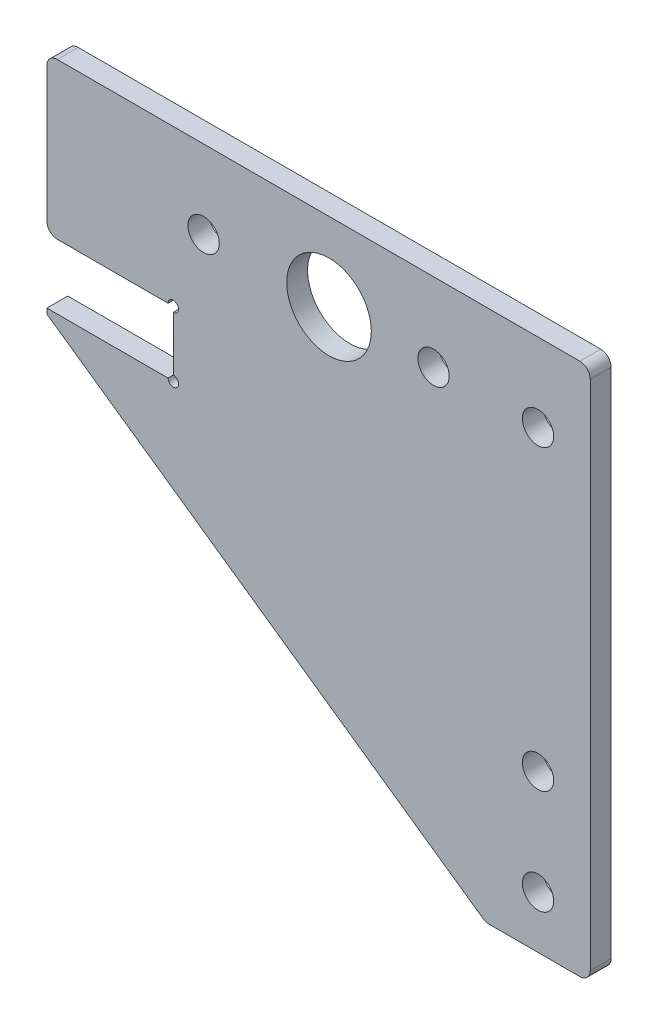
from build123d import *

# Parameters (mm, degrees)
SKETCH_1_R          = 1.5
SKETCH_1_R_2        = 4.05
EXTRUDE_1_DEPTH     = 2
SKETCH_2_R          = 0.5
CUT_EXTRUDE_1_DEPTH = 10
FILLET_1_R          = 1


with BuildPart() as part:
    # 草图1 → 凸台-拉伸1 (new body)
    with BuildSketch(Plane.XY):
        Polygon((-47, -14.091283395), (-5, -43.5), (5, -43.5), (5, 7.5), (-47, 7.5), (-47, -7.4), (-34.9, -7.4), (-34.9, -13.6), (-47, -13.6), align=None)
        with Locations((0, -38.5)):
            Circle(SKETCH_1_R, mode=Mode.SUBTRACT)
        with Locations((0, -28.5)):
            Circle(SKETCH_1_R, mode=Mode.SUBTRACT)
        with Locations((-32, 0)):
            Circle(SKETCH_1_R, mode=Mode.SUBTRACT)
        with Locations((-20, 0)):
            Circle(SKETCH_1_R_2, mode=Mode.SUBTRACT)
        with Locations((-10, 0)):
            Circle(SKETCH_1_R, mode=Mode.SUBTRACT)
        Circle(SKETCH_1_R, mode=Mode.SUBTRACT)
    extrude(amount=EXTRUDE_1_DEPTH)

    # 草图2 → 切除-拉伸1 (cut)
    with BuildSketch(Plane(origin=(0, 0, 0), x_dir=(-1, 0, 0), z_dir=(0, 0, -1))):
        with Locations((34.9, -7.4)):
            Circle(SKETCH_2_R)
        with Locations((34.9, -13.6)):
            Circle(SKETCH_2_R)
    extrude(amount=-CUT_EXTRUDE_1_DEPTH, mode=Mode.SUBTRACT)

    # 圆角1
    fillet_1_edges = [part.edges().sort_by_distance(p)[0] for p in [
        (-47, -7.4, 1),
        (-47, 7.5, 1),
        (5, 7.5, 1),
        (5, -43.5, 1),
        (-5, -43.5, 1),
    ]]
    fillet(fillet_1_edges, radius=FILLET_1_R)


solid = part.part
